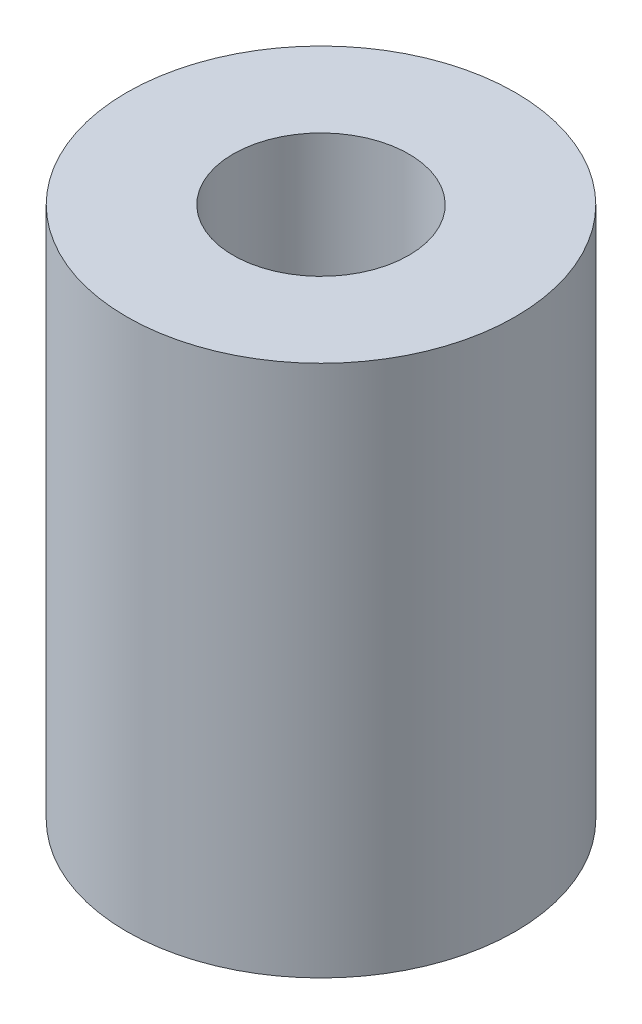
from build123d import *


with BuildPart() as part:
    # Sketch1 → Revolve1 (revolve)
    with BuildSketch(Plane.XY):
        Polygon((4.125, 10), (9.125, 10), (9.125, -15), (1.5, -15), (1.5, 0), (4.125, 0), align=None)
    revolve(axis=Axis((0, 10, 0), (0, -1, 0)))


solid = part.part
